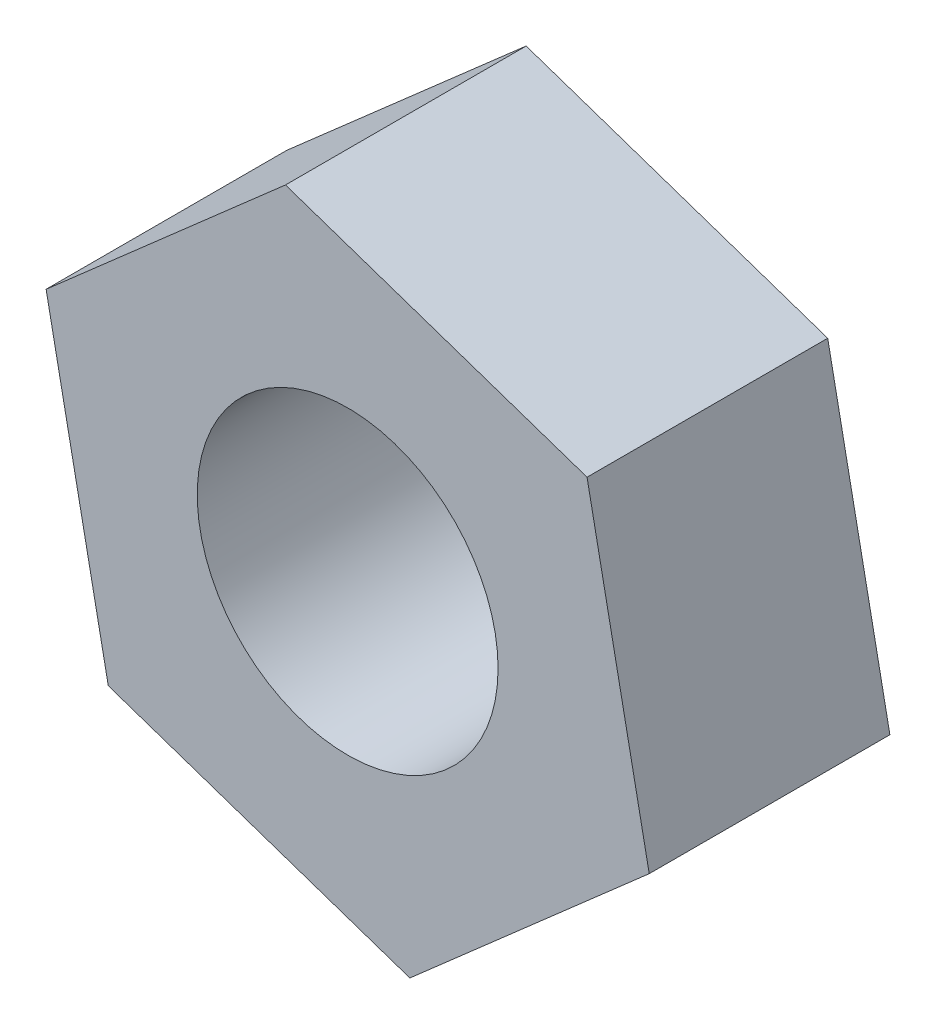
from build123d import *

# Parameters (mm, degrees)
SKETCH_1_R      = 1.5
EXTRUDE_1_DEPTH = 2.4


with BuildPart() as part:
    # 草图1 → 凸台-拉伸1 (new body)
    with BuildSketch(Plane.XY):
        Polygon((3.00710117, -1.020135229), (2.387013609, 2.094158391), (-0.620087562, 3.11429362), (-3.00710117, 1.020135229), (-2.387013609, -2.094158391), (0.620087562, -3.11429362), align=None)
        Circle(SKETCH_1_R, mode=Mode.SUBTRACT)
    extrude(amount=EXTRUDE_1_DEPTH)


solid = part.part
